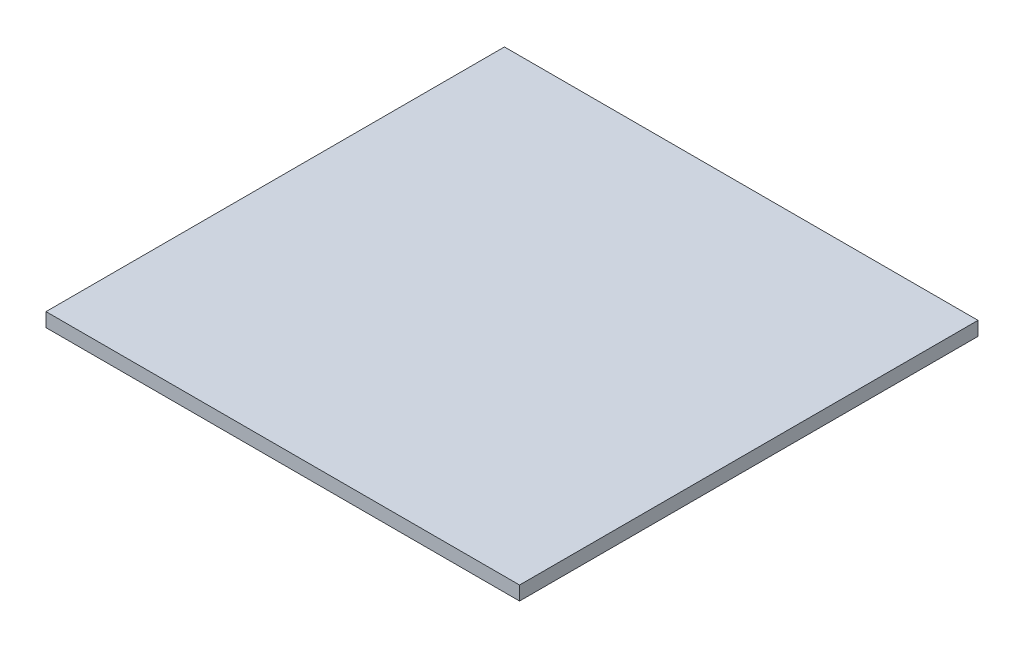
from build123d import *

# Parameters (mm, degrees)
SKETCH1_W           = 102.06
SKETCH1_H           = 98.8
BOSS_EXTRUDE1_DEPTH = 3


with BuildPart() as part:
    # Sketch1 → Boss-Extrude1 (new body)
    with BuildSketch(Plane(origin=(0, 0, 0), x_dir=(1, 0, 0), z_dir=(0, 1, 0))):
        with Locations((6.748457944, -28.701985981)):
            Rectangle(SKETCH1_W, SKETCH1_H)
    extrude(amount=BOSS_EXTRUDE1_DEPTH)


solid = part.part
